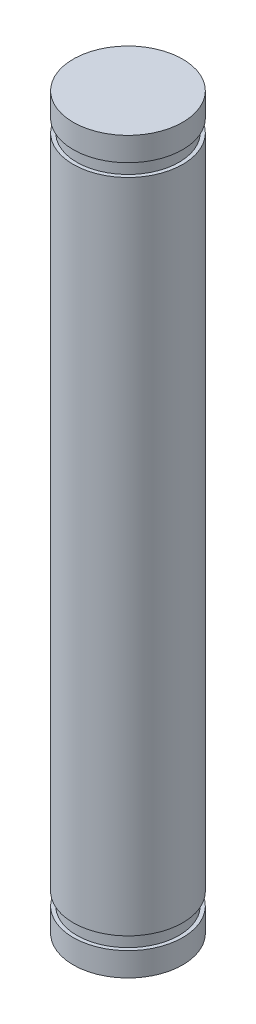
from build123d import *


with BuildPart() as part:
    # 草图1 → 旋转1 (revolve)
    with BuildSketch(Plane.XY):
        Polygon((0, -20), (3, -20), (3, -18.7), (2.8, -18.7), (2.8, -18), (3, -18), (3, 18), (2.8, 18), (2.8, 18.7), (3, 18.7), (3, 20), (0, 20), align=None)
    revolve(axis=Axis((0, 20, 0), (0, -1, 0)))


solid = part.part
